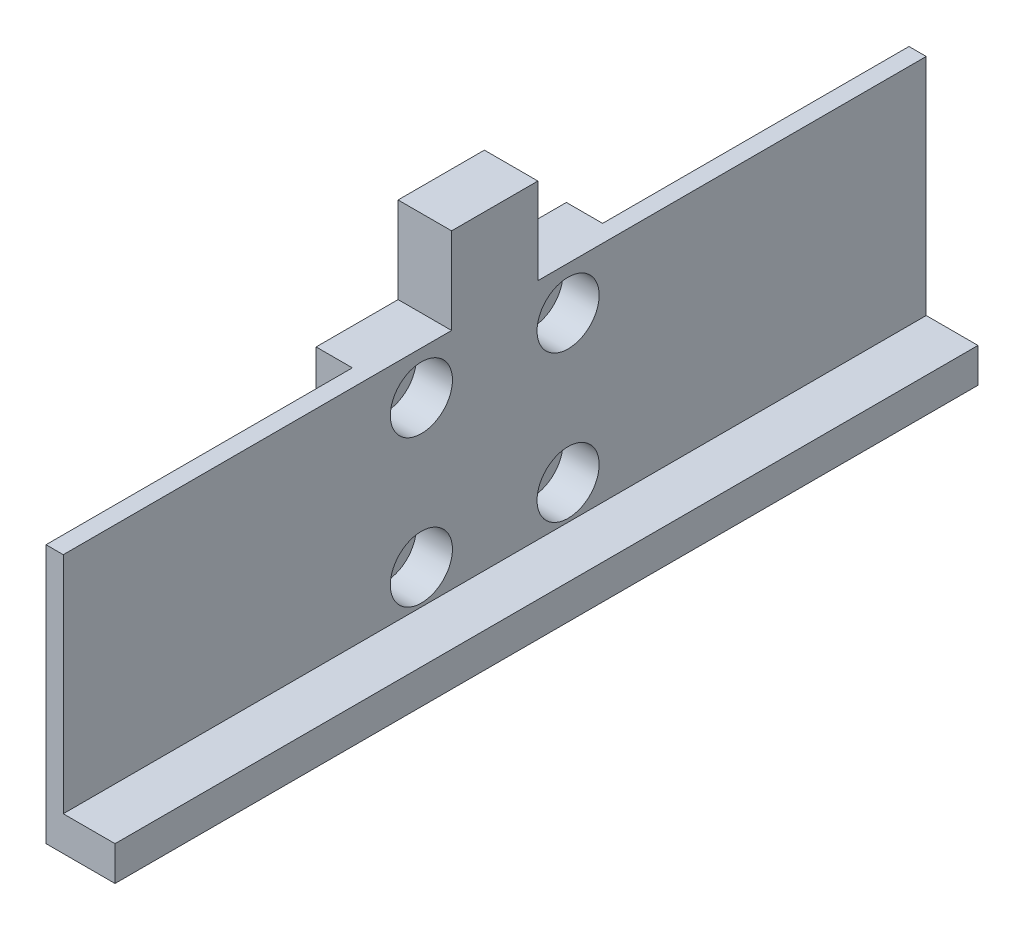
from build123d import *

# Parameters (mm, degrees)
SKETCH1_W               = 100
SKETCH1_H               = 26
BOSS_EXTRUDE1_DEPTH     = 2
BOSS_EXTRUDE2_DEPTH     = 100
SKETCH3_W               = 25
SKETCH3_H               = 28
BOSS_EXTRUDE3_DEPTH     = 4
SKETCH4_R               = 2.1
CUT_EXTRUDE1_DEPTH      = 106.39449701
SKETCH5_W               = 120
SKETCH5_H               = 46
SKETCH5_W_2             = 100
SKETCH5_H_2             = 26
CUT_EXTRUDE2_DEPTH      = 105.537074763
CUT_EXTRUDE2_DEPTH_BACK = 105.537074763
SKETCH6_W               = 100
SKETCH6_H               = 26
SKETCH6_R               = 3.6
BOSS_EXTRUDE4_DEPTH     = 4.2
SKETCH8_W               = 100
SKETCH8_H               = 4
BOSS_EXTRUDE5_DEPTH     = 6
SKETCH9_W               = 100
SKETCH9_H               = 4
BOSS_EXTRUDE6_DEPTH     = 10.2
SKETCH10_W              = 4
SKETCH10_H              = 37.5
CUT_EXTRUDE3_DEPTH      = 106.682732743
SKETCH11_W              = 4
SKETCH11_H              = 25
CUT_EXTRUDE4_DEPTH      = 107.737247482
SKETCH13_W              = 10
SKETCH13_H              = 10
BOSS_EXTRUDE7_DEPTH     = 6.2
SKETCH14_W              = 4.2
SKETCH14_H              = 35.5
CUT_EXTRUDE5_DEPTH      = 107.737247482


with BuildPart() as part:
    # Sketch1 → Boss-Extrude1 (new body)
    with BuildSketch(Plane(origin=(0, 0, 0), x_dir=(0, 0, -1), z_dir=(1, 0, 0))):
        with Locations((50, 13)):
            Rectangle(SKETCH1_W, SKETCH1_H)
    extrude(amount=BOSS_EXTRUDE1_DEPTH)

    # Sketch2 → Boss-Extrude2 (add)
    with BuildSketch(Plane.XY):
        Polygon((2, 26), (2, 28), (-12, 28), (-12, 24), (-10, 24), (-10, 26), align=None)
    extrude(amount=-BOSS_EXTRUDE2_DEPTH)

    # Sketch3 → Boss-Extrude3 (add)
    with BuildSketch(Plane(origin=(2, 0, 0), x_dir=(0, 0, -1), z_dir=(1, 0, 0))):
        with Locations((50, 14)):
            Rectangle(SKETCH3_W, SKETCH3_H)
    extrude(amount=BOSS_EXTRUDE3_DEPTH)

    # Sketch4 → Cut-Extrude1 (cut, through all)
    with BuildSketch(Plane(origin=(6, 0, 0), x_dir=(0, 0, -1), z_dir=(1, 0, 0))):
        with Locations((41.5, 21)):
            Circle(SKETCH4_R)
        with Locations((58.5, 21)):
            Circle(SKETCH4_R)
        with Locations((58.5, 4)):
            Circle(SKETCH4_R)
        with Locations((41.5, 4)):
            Circle(SKETCH4_R)
    extrude(amount=-CUT_EXTRUDE1_DEPTH, mode=Mode.SUBTRACT)


with BuildPart() as body_2:
    # Mirror1: mirrored copy
    add(part.part.mirror(Plane(origin=(6, 0, 0), x_dir=(0, 0, 1), z_dir=(1, 0, 0))))

    # Sketch5 → Cut-Extrude2 (cut, two sides)
    with BuildSketch(Plane(origin=(12, 0, 0), x_dir=(0, 0, -1), z_dir=(1, 0, 0))) as cut_extrude2_sk:
        with Locations((50, 13)):
            Rectangle(SKETCH5_W, SKETCH5_H)
        with Locations((50, 13)):
            Rectangle(SKETCH5_W_2, SKETCH5_H_2, mode=Mode.SUBTRACT)
    extrude(amount=CUT_EXTRUDE2_DEPTH, mode=Mode.SUBTRACT)
    extrude(cut_extrude2_sk.sketch, amount=-CUT_EXTRUDE2_DEPTH_BACK, mode=Mode.SUBTRACT)


with BuildPart() as body_2_2:
    # of the pieces the cut leaves, the one that is kept (cut_extrude2_keep)
    add(body_2.part.solids().sort_by_distance((12, 0, 0))[0])

    # Sketch6 → Boss-Extrude4 (add)
    with BuildSketch(Plane(origin=(12, 0, 0), x_dir=(0, 0, -1), z_dir=(1, 0, 0))):
        with Locations((50, 13)):
            Rectangle(SKETCH6_W, SKETCH6_H)
        with Locations((41.5, 21)):
            Circle(SKETCH6_R, mode=Mode.SUBTRACT)
        with Locations((58.5, 21)):
            Circle(SKETCH6_R, mode=Mode.SUBTRACT)
        with Locations((58.5, 4)):
            Circle(SKETCH6_R, mode=Mode.SUBTRACT)
        with Locations((41.5, 4)):
            Circle(SKETCH6_R, mode=Mode.SUBTRACT)
    extrude(amount=BOSS_EXTRUDE4_DEPTH)



with BuildPart() as body_2_3:
    # Sketch8 → Boss-Extrude5 (new body)
    with BuildSketch(Plane(origin=(16.2, 0, 0), x_dir=(0, 0, -1), z_dir=(1, 0, 0))):
        with Locations((50, -2)):
            Rectangle(SKETCH8_W, SKETCH8_H)
    extrude(amount=BOSS_EXTRUDE5_DEPTH)


with BuildPart() as body_2_2_1:
    add(body_2_2.part)

    add(body_2_3.part)  # Boss-Extrude6 merges body 2 3
    # Sketch9 → Boss-Extrude6 (add)
    with BuildSketch(Plane.ZY.offset(-16.2)):
        with Locations((-50, -2)):
            Rectangle(SKETCH9_W, SKETCH9_H)
    extrude(amount=BOSS_EXTRUDE6_DEPTH)

    # Sketch10 → Cut-Extrude3 (cut, through all)
    with BuildSketch(Plane(origin=(0, 0, 0), x_dir=(1, 0, 0), z_dir=(0, 1, 0))):
        with Locations((8, 81.25)):
            Rectangle(SKETCH10_W, SKETCH10_H)
        with Locations((8, 18.75)):
            Rectangle(SKETCH10_W, SKETCH10_H)
    extrude(amount=-CUT_EXTRUDE3_DEPTH, mode=Mode.SUBTRACT)

    # Sketch11 → Cut-Extrude4 (cut, through all)
    with BuildSketch(Plane(origin=(0, 26, 0), x_dir=(1, 0, 0), z_dir=(0, 1, 0))):
        with Locations((8, 50)):
            Rectangle(SKETCH11_W, SKETCH11_H)
    extrude(amount=-CUT_EXTRUDE4_DEPTH, mode=Mode.SUBTRACT)

    # Sketch13 → Boss-Extrude7 (add)
    with BuildSketch(Plane.ZY.offset(-10)):
        with Locations((-50, 31)):
            Rectangle(SKETCH13_W, SKETCH13_H)
    extrude(amount=-BOSS_EXTRUDE7_DEPTH)

    # Sketch14 → Cut-Extrude5 (cut, through all)
    with BuildSketch(Plane(origin=(0, 26, 0), x_dir=(1, 0, 0), z_dir=(0, 1, 0))):
        with Locations((12.1, 17.75)):
            Rectangle(SKETCH14_W, SKETCH14_H)
        with Locations((12.1, 82.25)):
            Rectangle(SKETCH14_W, SKETCH14_H)
    extrude(amount=-CUT_EXTRUDE5_DEPTH, mode=Mode.SUBTRACT)


solid = body_2_2_1.part
